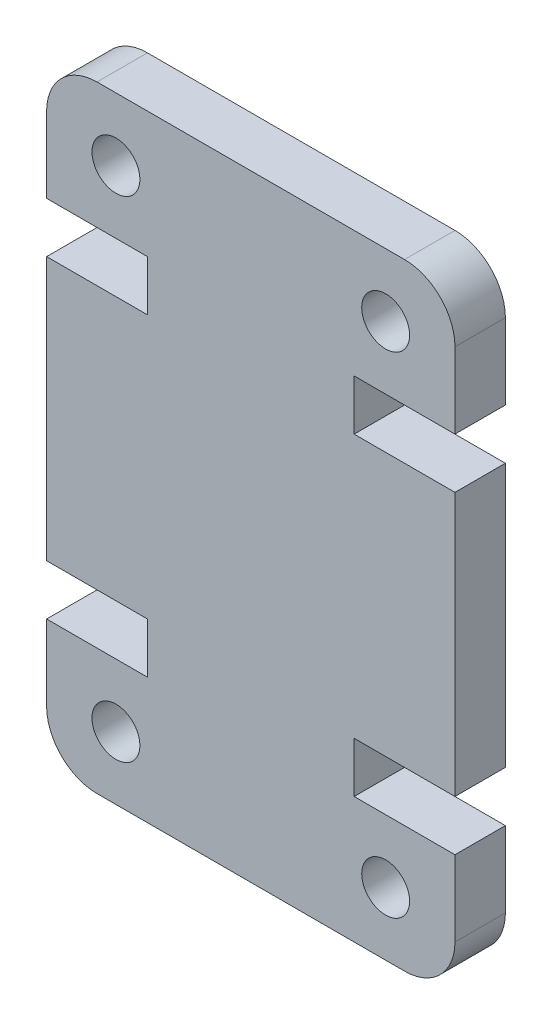
from build123d import *

# Parameters (mm, degrees)
SKETCH1_R           = 0.95
BOSS_EXTRUDE1_DEPTH = 4
SKETCH2_W           = 16.2
SKETCH2_H           = 24.45
CUT_EXTRUDE1_DEPTH  = 2


with BuildPart() as part:
    # Sketch1 → Boss-Extrude1 (new body)
    with BuildSketch(Plane.XY):
        with BuildLine():
            Line((0, 17.45), (0, 7))
            Line((0, 7), (4, 7))
            Line((4, 7), (4, 5))
            Line((4, 5), (0, 5))
            Line((0, 5), (0, 2))
            ThreePointArc((0, 2), (0.585786438, 0.585786438), (2, 0))
            Line((2, 0), (14.2, 0))
            ThreePointArc((14.2, 0), (15.614213562, 0.585786438), (16.2, 2))
            Line((16.2, 2), (16.2, 5))
            Line((16.2, 5), (12.2, 5))
            Line((12.2, 5), (12.2, 7))
            Line((12.2, 7), (16.2, 7))
            Line((16.2, 7), (16.2, 17.45))
            Line((16.2, 17.45), (12.2, 17.45))
            Line((12.2, 17.45), (12.2, 19.45))
            Line((12.2, 19.45), (16.2, 19.45))
            Line((16.2, 19.45), (16.2, 22.45))
            ThreePointArc((16.2, 22.45), (15.614213562, 23.864213562), (14.2, 24.45))
            Line((14.2, 24.45), (2, 24.45))
            ThreePointArc((2, 24.45), (0.585786438, 23.864213562), (0, 22.45))
            Line((0, 22.45), (0, 19.45))
            Line((0, 19.45), (4, 19.45))
            Line((4, 19.45), (4, 17.45))
            Line((4, 17.45), (0, 17.45))
        make_face()
        with Locations((13.45, 2.5)):
            Circle(SKETCH1_R, mode=Mode.SUBTRACT)
        with Locations((2.75, 21.95)):
            Circle(SKETCH1_R, mode=Mode.SUBTRACT)
        with Locations((2.75, 2.5)):
            Circle(SKETCH1_R, mode=Mode.SUBTRACT)
        with Locations((13.45, 21.95)):
            Circle(SKETCH1_R, mode=Mode.SUBTRACT)
    extrude(amount=BOSS_EXTRUDE1_DEPTH)

    # Sketch2 → Cut-Extrude1 (cut)
    with BuildSketch(Plane(origin=(0, 0, 0), x_dir=(-1, 0, 0), z_dir=(0, 0, -1))):
        with Locations((-8.1, 12.225)):
            Rectangle(SKETCH2_W, SKETCH2_H)
    extrude(amount=-CUT_EXTRUDE1_DEPTH, mode=Mode.SUBTRACT)


solid = part.part
